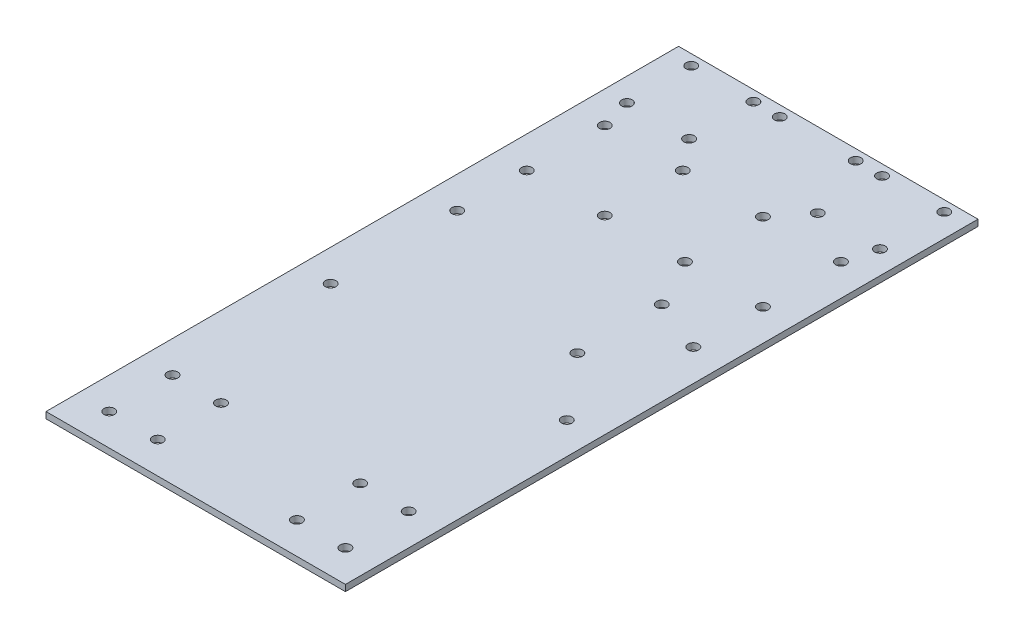
from build123d import *

# Parameters (mm, degrees)
SKETCH_1_W          = 142
SKETCH_1_H          = 300
EXTRUDE_1_DEPTH     = 3
SKETCH_2_R          = 2.5
CUT_EXTRUDE_1_DEPTH = 3
SKETCH_3_R          = 2.5
CUT_EXTRUDE_2_DEPTH = 3
SKETCH_4_R          = 2.5
CUT_EXTRUDE_3_DEPTH = 3
SKETCH_5_R          = 2.5
CUT_EXTRUDE_4_DEPTH = 3
SKETCH_6_R          = 2.5
CUT_EXTRUDE_5_DEPTH = 3


with BuildPart() as part:
    # 草图1 → 凸台-拉伸1 (new body)
    with BuildSketch(Plane(origin=(0, 0, 0), x_dir=(1, 0, 0), z_dir=(0, 1, 0))):
        Rectangle(SKETCH_1_W, SKETCH_1_H)
    extrude(amount=EXTRUDE_1_DEPTH)

    # 草图2 → 切除-拉伸1 (cut)
    with BuildSketch(Plane(origin=(0, 3, 0), x_dir=(1, 0, 0), z_dir=(0, 1, 0))):
        with Locations((-60, 114.5)):
            Circle(SKETCH_2_R)
        with Locations((-60, 145)):
            Circle(SKETCH_2_R)
        with Locations((-30.5, 145)):
            Circle(SKETCH_2_R)
        with Locations((-30.5, 114.5)):
            Circle(SKETCH_2_R)
        with Locations((-18, 145)):
            Circle(SKETCH_2_R)
    cut_extrude_1 = extrude(amount=-CUT_EXTRUDE_1_DEPTH, mode=Mode.SUBTRACT)

    # 镜向1: 切除-拉伸1 across plane
    add(cut_extrude_1.mirror(Plane(origin=(0, 0, 0), x_dir=(0, 0, 1), z_dir=(1, 0, 0))), mode=Mode.SUBTRACT)

    # 草图3 → 切除-拉伸2 (cut)
    with BuildSketch(Plane(origin=(0, 3, 0), x_dir=(1, 0, 0), z_dir=(0, 1, 0))):
        with Locations((-56, 100)):
            Circle(SKETCH_3_R)
        with Locations((-19, 100)):
            Circle(SKETCH_3_R)
        with Locations((-56, 63)):
            Circle(SKETCH_3_R)
        with Locations((-19, 63)):
            Circle(SKETCH_3_R)
    cut_extrude_2 = extrude(amount=-CUT_EXTRUDE_2_DEPTH, mode=Mode.SUBTRACT)

    # 镜向2: 切除-拉伸2 across plane
    add(cut_extrude_2.mirror(Plane(origin=(0, 0, 0), x_dir=(0, 0, 1), z_dir=(1, 0, 0))), mode=Mode.SUBTRACT)

    # 草图4 → 切除-拉伸3 (cut)
    with BuildSketch(Plane(origin=(0, 3, 0), x_dir=(1, 0, 0), z_dir=(0, 1, 0))):
        with Locations((31, 40)):
            Circle(SKETCH_4_R)
        with Locations((31, 0)):
            Circle(SKETCH_4_R)
    extrude(amount=-CUT_EXTRUDE_3_DEPTH, mode=Mode.SUBTRACT)

    # 草图5 → 切除-拉伸4 (cut)
    with BuildSketch(Plane(origin=(0, 3, 0), x_dir=(1, 0, 0), z_dir=(0, 1, 0))):
        with Locations((-56, -30)):
            Circle(SKETCH_5_R)
        with Locations((-56, 30)):
            Circle(SKETCH_5_R)
    cut_extrude_4 = extrude(amount=-CUT_EXTRUDE_4_DEPTH, mode=Mode.SUBTRACT)

    # 镜向3: 切除-拉伸4 across plane
    add(cut_extrude_4.mirror(Plane(origin=(0, 0, 0), x_dir=(0, 0, 1), z_dir=(1, 0, 0))), mode=Mode.SUBTRACT)

    # 草图6 → 切除-拉伸5 (cut)
    with BuildSketch(Plane(origin=(0, 3, 0), x_dir=(1, 0, 0), z_dir=(0, 1, 0))):
        with Locations((-33, -105)):
            Circle(SKETCH_6_R)
        with Locations((-33, -135)):
            Circle(SKETCH_6_R)
        with Locations((-56, -135)):
            Circle(SKETCH_6_R)
        with Locations((-56, -105)):
            Circle(SKETCH_6_R)
    cut_extrude_5 = extrude(amount=-CUT_EXTRUDE_5_DEPTH, mode=Mode.SUBTRACT)

    # 镜向4: 切除-拉伸5 across plane
    add(cut_extrude_5.mirror(Plane(origin=(0, 0, 0), x_dir=(0, 0, 1), z_dir=(1, 0, 0))), mode=Mode.SUBTRACT)


solid = part.part
